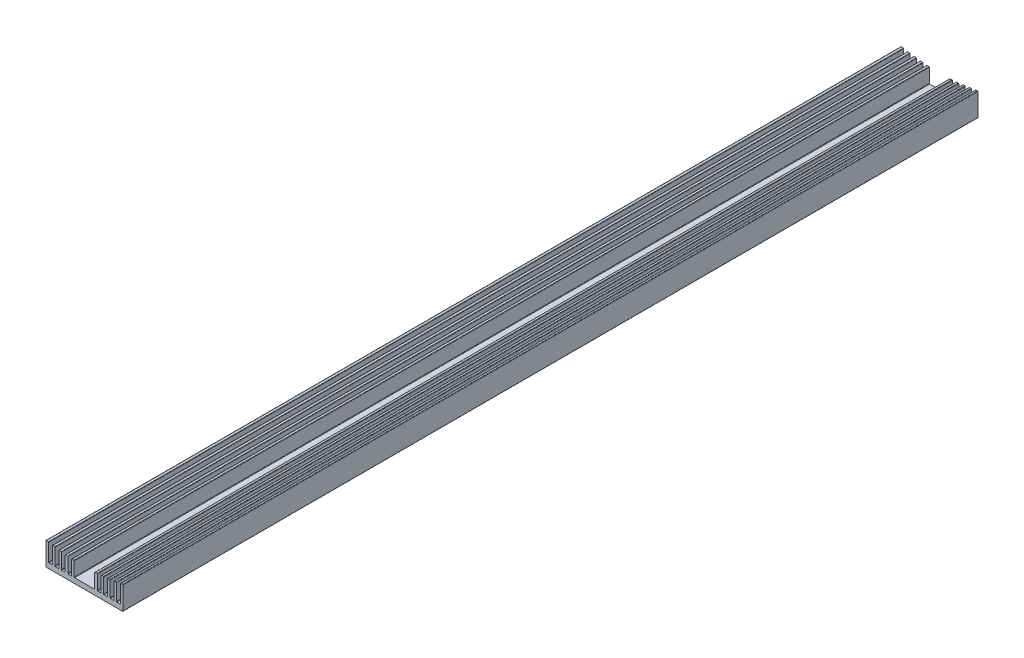
from build123d import *

# Parameters (mm, degrees)
EXTRUDE_1_DEPTH = 1000


with BuildPart() as part:
    # Model → Бобышка-Вытянуть1 (new body)
    with BuildSketch(Plane.XY):
        with BuildLine():
            Line((-45, 0.5), (-45, 26.894643722))
            ThreePointArc((-45, 26.894643722), (-44.817095334, 27.281232068), (-44.402197802, 27.384985164))
            Line((-44.402197802, 27.384985164), (-42.406593407, 26.996231342))
            ThreePointArc((-42.406593407, 26.996231342), (-42.114835557, 26.823857), (-42, 26.505033614))
            Line((-42, 26.505033614), (-42, 6.5))
            ThreePointArc((-42, 6.5), (-41.853553391, 6.146446609), (-41.5, 6))
            Line((-41.5, 6), (-38, 6))
            ThreePointArc((-38, 6), (-37.646446609, 6.146446609), (-37.5, 6.5))
            Line((-37.5, 6.5), (-37.5, 25.528955097))
            ThreePointArc((-37.5, 25.528955097), (-37.323527943, 25.910176385), (-36.918681319, 26.022298052))
            Line((-36.918681319, 26.022298052), (-34.923076923, 25.70247728))
            ThreePointArc((-34.923076923, 25.70247728), (-34.620222737, 25.533651691), (-34.5, 25.208429873))
            Line((-34.5, 25.208429873), (-34.5, 6.5))
            ThreePointArc((-34.5, 6.5), (-34.353553391, 6.146446609), (-34, 6))
            Line((-34, 6), (-30.5, 6))
            ThreePointArc((-30.5, 6), (-30.146446609, 6.146446609), (-30, 6.5))
            Line((-30, 6.5), (-30, 24.420745635))
            ThreePointArc((-30, 24.420745635), (-29.829835124, 24.796523217), (-29.435164835, 24.916524216))
            Line((-29.435164835, 24.916524216), (-27.43956044, 24.664537804))
            ThreePointArc((-27.43956044, 24.664537804), (-27.125687443, 24.499700959), (-27, 24.168204187))
            Line((-27, 24.168204187), (-27, 6.5))
            ThreePointArc((-27, 6.5), (-26.853553391, 6.146446609), (-26.5, 6))
            Line((-26.5, 6), (-23, 6))
            ThreePointArc((-23, 6), (-22.646446609, 6.146446609), (-22.5, 6.5))
            Line((-22.5, 6.5), (-22.5, 23.56623485))
            ThreePointArc((-22.5, 23.56623485), (-22.336023939, 23.936488698), (-21.951648352, 24.063891477))
            Line((-21.951648352, 24.063891477), (-19.956043956, 23.878890172))
            ThreePointArc((-19.956043956, 23.878890172), (-19.631233121, 23.718481187), (-19.5, 23.380826054))
            Line((-19.5, 23.380826054), (-19.5, 6.5))
            ThreePointArc((-19.5, 6.5), (-19.353553391, 6.146446609), (-19, 6))
            Line((-19, 6), (-15.5, 6))
            ThreePointArc((-15.5, 6), (-15.146446609, 6.146446609), (-15, 6.5))
            Line((-15, 6.5), (-15, 22.962558154))
            ThreePointArc((-15, 22.962558154), (-14.842100814, 23.327204603), (-14.468131868, 23.461541543))
            Line((-14.468131868, 23.461541543), (-12.472527473, 23.342910858))
            ThreePointArc((-12.472527473, 23.342910858), (-12.13686348, 23.187369337), (-12, 22.843666168))
            Line((-12, 22.843666168), (-12, 6.5))
            ThreePointArc((-12, 6.5), (-11.853553391, 6.146446609), (-11.5, 6))
            Line((-11.5, 6), (11.5, 6))
            ThreePointArc((11.5, 6), (11.853553391, 6.146446609), (12, 6.5))
            Line((12, 6.5), (12, 22.843666168))
            ThreePointArc((12, 22.843666168), (12.13686348, 23.187369337), (12.472527473, 23.342910858))
            Line((12.472527473, 23.342910858), (14.468131868, 23.461541543))
            ThreePointArc((14.468131868, 23.461541543), (14.842100814, 23.327204603), (15, 22.962558154))
            Line((15, 22.962558154), (15, 6.5))
            ThreePointArc((15, 6.5), (15.146446609, 6.146446609), (15.5, 6))
            Line((15.5, 6), (19, 6))
            ThreePointArc((19, 6), (19.353553391, 6.146446609), (19.5, 6.5))
            Line((19.5, 6.5), (19.5, 23.380826054))
            ThreePointArc((19.5, 23.380826054), (19.631233121, 23.718481187), (19.956043956, 23.878890172))
            Line((19.956043956, 23.878890172), (21.951648352, 24.063891477))
            ThreePointArc((21.951648352, 24.063891477), (22.336023939, 23.936488698), (22.5, 23.56623485))
            Line((22.5, 23.56623485), (22.5, 6.5))
            ThreePointArc((22.5, 6.5), (22.646446609, 6.146446609), (23, 6))
            Line((23, 6), (26.5, 6))
            ThreePointArc((26.5, 6), (26.853553391, 6.146446609), (27, 6.5))
            Line((27, 6.5), (27, 24.168204187))
            ThreePointArc((27, 24.168204187), (27.125687443, 24.499700959), (27.43956044, 24.664537804))
            Line((27.43956044, 24.664537804), (29.435164835, 24.916524216))
            ThreePointArc((29.435164835, 24.916524216), (29.829835124, 24.796523217), (30, 24.420745635))
            Line((30, 24.420745635), (30, 6.5))
            ThreePointArc((30, 6.5), (30.146446609, 6.146446609), (30.5, 6))
            Line((30.5, 6), (34, 6))
            ThreePointArc((34, 6), (34.353553391, 6.146446609), (34.5, 6.5))
            Line((34.5, 6.5), (34.5, 25.208429873))
            ThreePointArc((34.5, 25.208429873), (34.620222737, 25.533651691), (34.923076923, 25.70247728))
            Line((34.923076923, 25.70247728), (36.918681319, 26.022298052))
            ThreePointArc((36.918681319, 26.022298052), (37.323527943, 25.910176385), (37.5, 25.528955097))
            Line((37.5, 25.528955097), (37.5, 6.5))
            ThreePointArc((37.5, 6.5), (37.646446609, 6.146446609), (38, 6))
            Line((38, 6), (41.5, 6))
            ThreePointArc((41.5, 6), (41.853553391, 6.146446609), (42, 6.5))
            Line((42, 6.5), (42, 26.505033614))
            ThreePointArc((42, 26.505033614), (42.114835557, 26.823857), (42.406593407, 26.996231342))
            Line((42.406593407, 26.996231342), (44.402197802, 27.384985164))
            ThreePointArc((44.402197802, 27.384985164), (44.817095334, 27.281232068), (45, 26.894643722))
            Line((45, 26.894643722), (45, 0.5))
            ThreePointArc((45, 0.5), (44.853553391, 0.146446609), (44.5, 0))
            Line((44.5, 0), (-44.5, 0))
            ThreePointArc((-44.5, 0), (-44.853553391, 0.146446609), (-45, 0.5))
        make_face()
    extrude(amount=EXTRUDE_1_DEPTH)


solid = part.part
